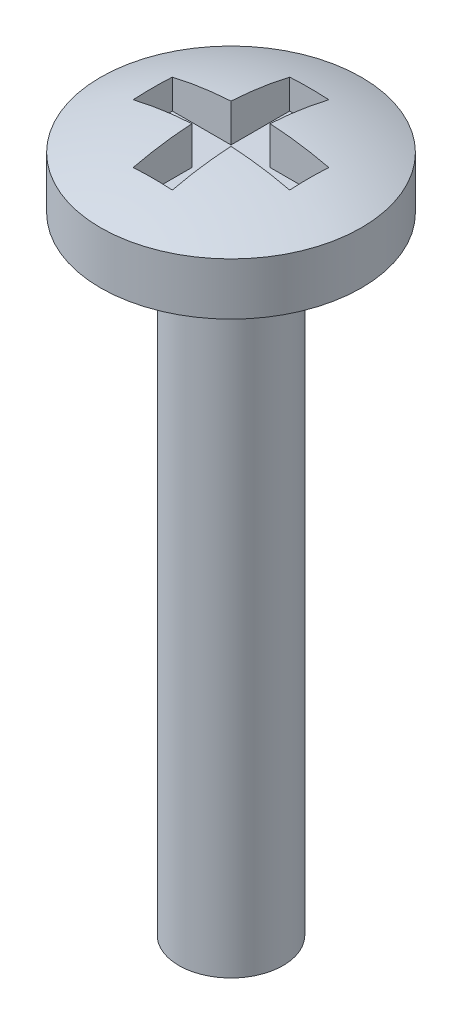
from build123d import *

# Parameters (mm, degrees)
SKETCH1_R           = 1
BOSS_EXTRUDE1_DEPTH = 12
SKETCH2_R           = 2.5
BOSS_EXTRUDE2_DEPTH = 1
DOME1_FACE_RADIUS   = 2.5
DOME1_HEIGHT        = 0.5
SKETCH3_W           = 1.125
SKETCH3_H           = 0.75
SKETCH3_W_2         = 0.75
SKETCH3_H_2         = 1.125
CUT_EXTRUDE1_DEPTH  = 0.75


with BuildPart() as part:
    # Sketch1 → Boss-Extrude1 (new body)
    with BuildSketch(Plane(origin=(0, 0, 0), x_dir=(1, 0, 0), z_dir=(0, 1, 0))):
        Circle(SKETCH1_R)
    extrude(amount=BOSS_EXTRUDE1_DEPTH)

    # Sketch2 → Boss-Extrude2 (add)
    with BuildSketch(Plane(origin=(0, 12, 0), x_dir=(1, 0, 0), z_dir=(0, 1, 0))):
        Circle(SKETCH2_R)
    extrude(amount=BOSS_EXTRUDE2_DEPTH)

    # Dome1: a dome of height H over a round flat face of radius A is a cap of a sphere of radius (A * A + H * H) / (2 * H)
    dome1_r = (DOME1_FACE_RADIUS * DOME1_FACE_RADIUS + DOME1_HEIGHT * DOME1_HEIGHT) / (2 * DOME1_HEIGHT)
    dome1_base = Plane((0, 13, 0), z_dir=(0, 1, 0))
    with Locations(dome1_base.offset(DOME1_HEIGHT - dome1_r)):
        dome1_ball = Sphere(dome1_r, mode=Mode.PRIVATE)
    add(split(dome1_ball, bisect_by=dome1_base, keep=Keep.TOP, mode=Mode.PRIVATE))

    # Sketch3 → Cut-Extrude1 (cut)
    with BuildSketch(Plane(origin=(0, 13.5, 0), x_dir=(1, 0, 0), z_dir=(0, 1, 0))):
        with Locations((-0.9375, 0)):
            Rectangle(SKETCH3_W, SKETCH3_H)
        Rectangle(SKETCH3_W_2, SKETCH3_H)
        with Locations((0, 0.9375)):
            Rectangle(SKETCH3_W_2, SKETCH3_H_2)
        with Locations((0.9375, 0)):
            Rectangle(SKETCH3_W, SKETCH3_H)
        with Locations((0, -0.9375)):
            Rectangle(SKETCH3_W_2, SKETCH3_H_2)
    extrude(amount=-CUT_EXTRUDE1_DEPTH, mode=Mode.SUBTRACT)


solid = part.part
